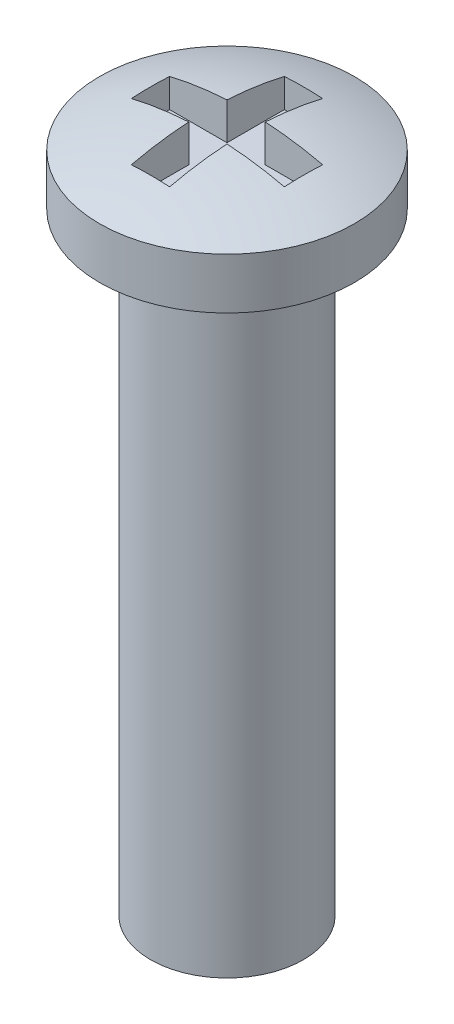
from build123d import *

# Parameters (mm, degrees)
SKETCH1_R           = 1.5
BOSS_EXTRUDE1_DEPTH = 12
SKETCH2_R           = 2.5
BOSS_EXTRUDE2_DEPTH = 1
DOME1_FACE_RADIUS   = 2.5
DOME1_HEIGHT        = 0.5
SKETCH3_W           = 1.125
SKETCH3_H           = 0.75
SKETCH3_W_2         = 0.75
SKETCH3_H_2         = 1.125
CUT_EXTRUDE1_DEPTH  = 0.75


with BuildPart() as part:
    # Sketch1 → Boss-Extrude1 (new body)
    with BuildSketch(Plane(origin=(0, 0, 0), x_dir=(1, 0, 0), z_dir=(0, 1, 0))):
        Circle(SKETCH1_R)
    extrude(amount=BOSS_EXTRUDE1_DEPTH)

    # Sketch2 → Boss-Extrude2 (add)
    with BuildSketch(Plane(origin=(0, 12, 0), x_dir=(1, 0, 0), z_dir=(0, 1, 0))):
        Circle(SKETCH2_R)
    extrude(amount=BOSS_EXTRUDE2_DEPTH)

    # Dome1: a dome of height H over a round flat face of radius A is a cap of a sphere of radius (A * A + H * H) / (2 * H)
    dome1_r = (DOME1_FACE_RADIUS * DOME1_FACE_RADIUS + DOME1_HEIGHT * DOME1_HEIGHT) / (2 * DOME1_HEIGHT)
    dome1_base = Plane((0, 13, 0), z_dir=(0, 1, 0))
    with Locations(dome1_base.offset(DOME1_HEIGHT - dome1_r)):
        dome1_ball = Sphere(dome1_r, mode=Mode.PRIVATE)
    add(split(dome1_ball, bisect_by=dome1_base, keep=Keep.TOP, mode=Mode.PRIVATE))

    # Sketch3 → Cut-Extrude1 (cut)
    with BuildSketch(Plane(origin=(0, 13.5, 0), x_dir=(1, 0, 0), z_dir=(0, 1, 0))):
        with Locations((-0.9375, 0)):
            Rectangle(SKETCH3_W, SKETCH3_H)
        Rectangle(SKETCH3_W_2, SKETCH3_H)
        with Locations((0, 0.9375)):
            Rectangle(SKETCH3_W_2, SKETCH3_H_2)
        with Locations((0.9375, 0)):
            Rectangle(SKETCH3_W, SKETCH3_H)
        with Locations((0, -0.9375)):
            Rectangle(SKETCH3_W_2, SKETCH3_H_2)
    extrude(amount=-CUT_EXTRUDE1_DEPTH, mode=Mode.SUBTRACT)


solid = part.part
